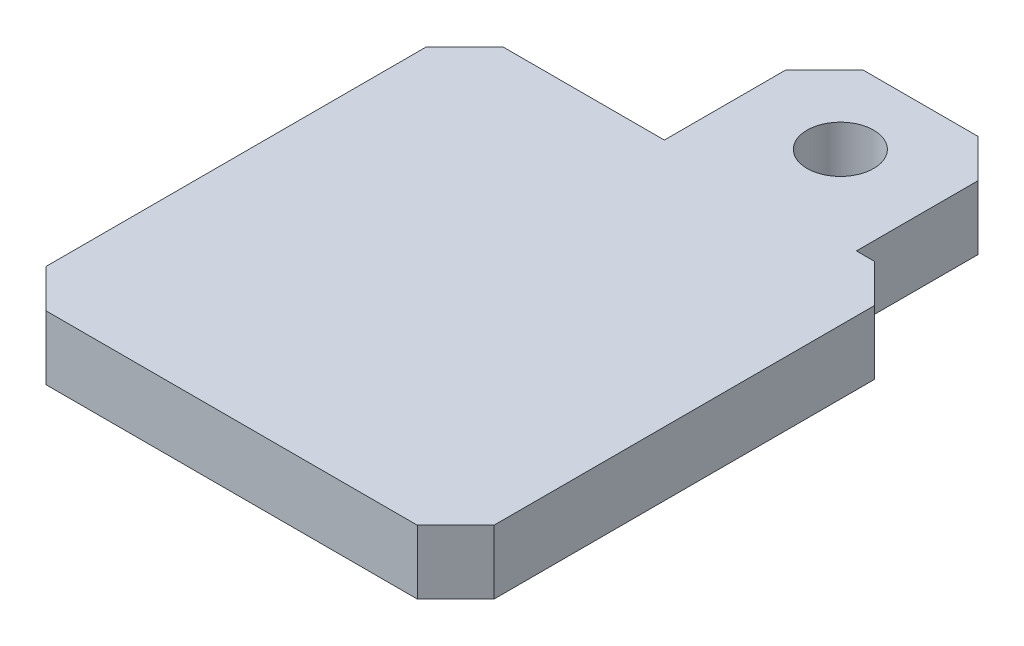
from build123d import *

# Parameters (mm, degrees)
SKETCH1_W           = 35
SKETCH1_H           = 0.7
SKETCH1_H_2         = 35
BOSS_EXTRUDE1_DEPTH = 5
CHAMFER1_SIZE       = 3
SKETCH4_R           = 2.6
SKETCH4_R_2         = 1.58
BOSS_EXTRUDE2_DEPTH = 1


with BuildPart() as part:
    # Sketch1 → Boss-Extrude1 (new body)
    with BuildSketch(Plane(origin=(0, 0, 0), x_dir=(1, 0, 0), z_dir=(0, 1, 0))):
        with BuildLine():
            Line((7.5, 17.5), (13.1, 17.5))
            Line((13.1, 17.5), (13.1, 30))
            Line((13.1, 30), (7.5, 30))
            Line((7.5, 30), (7.5, 25.524823935))
            ThreePointArc((7.5, 25.524823935), (8.018677324, 24.703939201), (8.2, 23.75))
            ThreePointArc((8.2, 23.75), (8.018677324, 22.796060799), (7.5, 21.975176065))
            Line((7.5, 21.975176065), (7.5, 17.5))
        make_face()
        with BuildLine():
            Line((-1.9, 30), (-1.9, 17.5))
            Line((-1.9, 17.5), (7.5, 17.5))
            Line((7.5, 17.5), (7.5, 21.975176065))
            ThreePointArc((7.5, 21.975176065), (3, 23.75), (7.5, 25.524823935))
            Line((7.5, 25.524823935), (7.5, 30))
            Line((7.5, 30), (-1.9, 30))
        make_face()
        with Locations((0, -17.85)):
            Rectangle(SKETCH1_W, SKETCH1_H)
        Rectangle(SKETCH1_W, SKETCH1_H_2)
    extrude(amount=BOSS_EXTRUDE1_DEPTH)

    # Chamfer1
    chamfer1_edges = [part.edges().sort_by_distance(p)[0] for p in [
        (-1.9, 2.5, -30),
        (13.1, 2.5, -30),
        (17.5, 2.5, -17.5),
        (17.5, 2.5, 18.2),
        (-17.5, 2.5, 18.2),
        (-17.5, 2.5, -17.5),
    ]]
    chamfer(chamfer1_edges, length=CHAMFER1_SIZE)

    # Sketch4 → Boss-Extrude2 (add)
    with BuildSketch(Plane(origin=(0, 0.3, 0), x_dir=(1, 0, 0), z_dir=(0, 1, 0))):
        with Locations((5.6, 23.75)):
            Circle(SKETCH4_R)
        with Locations((5.6, 23.75)):
            Circle(SKETCH4_R_2, mode=Mode.SUBTRACT)
    extrude(amount=BOSS_EXTRUDE2_DEPTH)


solid = part.part
